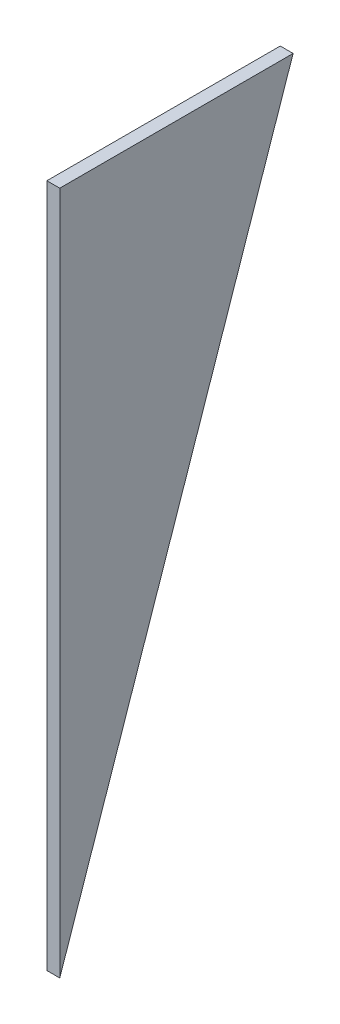
from build123d import *

# Parameters (mm, degrees)
EXTRUDE2_DEPTH = 16


with BuildPart() as part:
    # Sketch1 → Extrude2 (new body)
    with BuildSketch(Plane(origin=(0, 0, 0), x_dir=(0, 0, -1), z_dir=(1, 0, 0))):
        Polygon((290, 850), (0, 0), (0, 850), align=None)
    extrude(amount=EXTRUDE2_DEPTH)


solid = part.part
